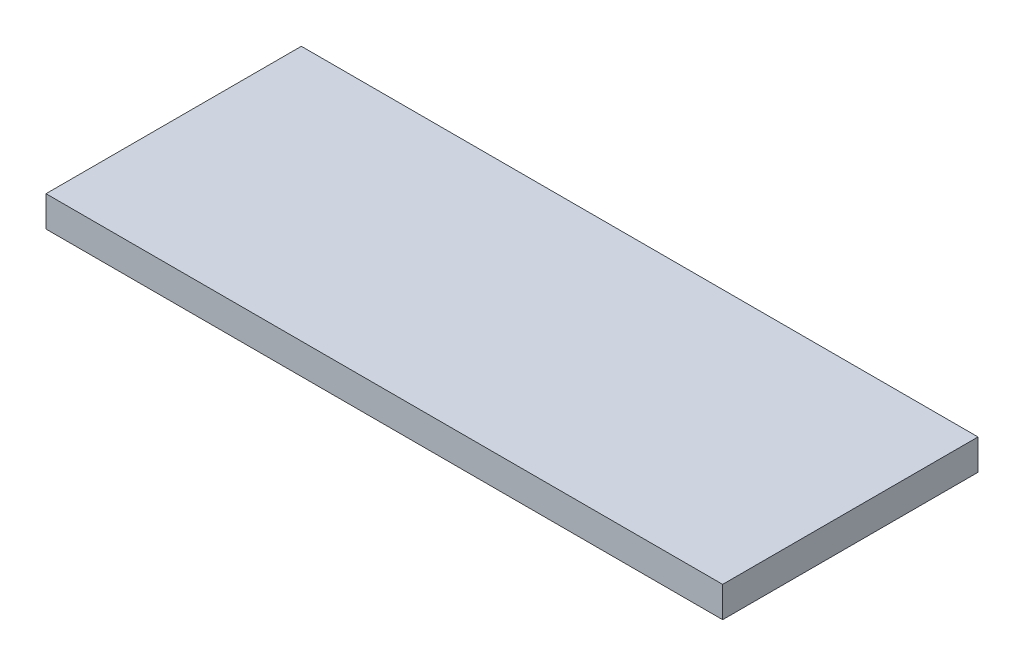
from build123d import *

# Parameters (mm, degrees)
SKETCH1_W           = 132.5
SKETCH1_H           = 50
BOSS_EXTRUDE1_DEPTH = 6


with BuildPart() as part:
    # Sketch1 → Boss-Extrude1 (new body)
    with BuildSketch(Plane(origin=(0, 0, 0), x_dir=(1, 0, 0), z_dir=(0, 1, 0))):
        Rectangle(SKETCH1_W, SKETCH1_H)
    extrude(amount=BOSS_EXTRUDE1_DEPTH)


solid = part.part
